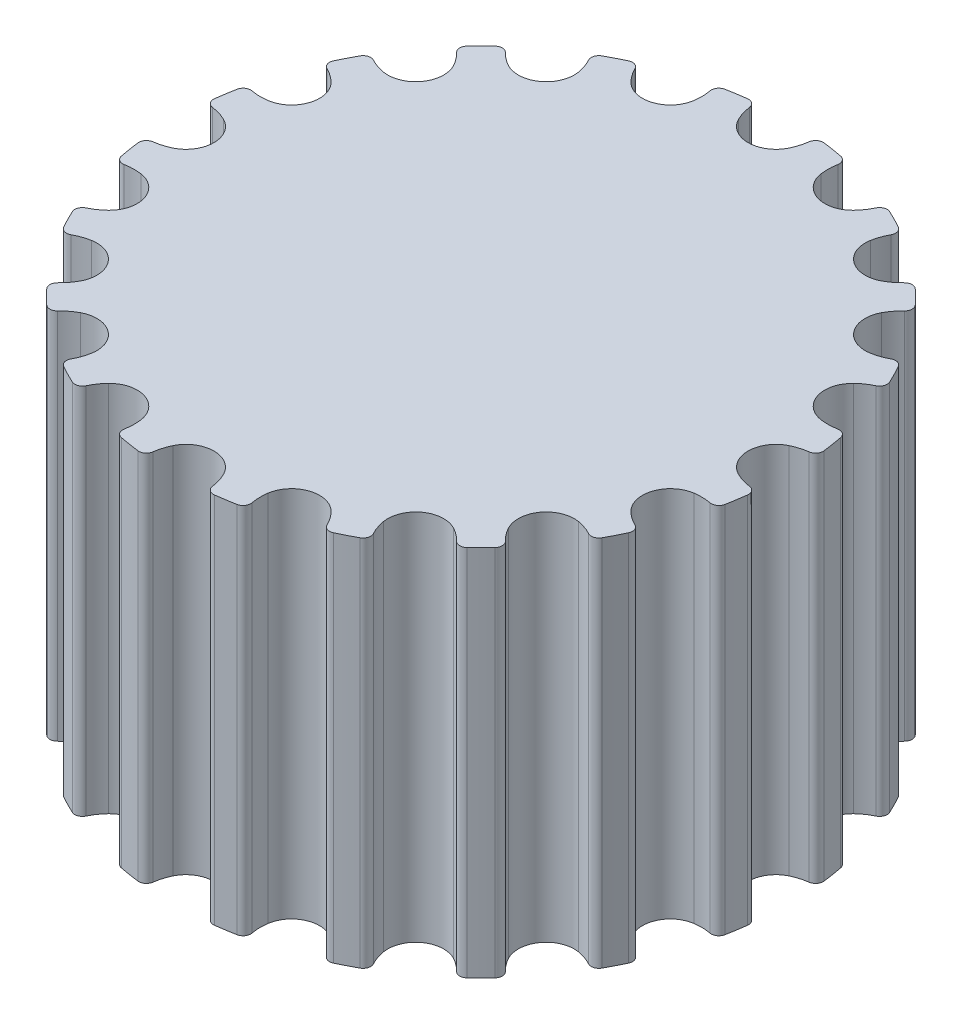
from build123d import *

# Parameters (mm, degrees)
SKETCH1_R           = 6.1
BOSS_EXTRUDE1_DEPTH = 7.4
CUT_EXTRUDE2_DEPTH  = 7.4
CIRPATTERN1_COUNT   = 20


with BuildPart() as part:
    # Sketch1 → Boss-Extrude1 (new body)
    with BuildSketch(Plane(origin=(0, 0, 0), x_dir=(1, 0, 0), z_dir=(0, 1, 0))):
        Circle(SKETCH1_R)
    extrude(amount=BOSS_EXTRUDE1_DEPTH)

    # Sketch2 → Cut-Extrude2 (cut)
    with BuildSketch(Plane(origin=(0, 7.4, 0), x_dir=(1, 0, 0), z_dir=(0, 1, 0))):
        with BuildLine():
            Line((-38.373637849, 1.335743881), (-0.758991905, 6.05259707))
            ThreePointArc((-0.758991905, 6.05259707), (-0.648582224, 6.02243319), (-0.591589713, 5.923175892))
            ThreePointArc((-0.591589713, 5.923175892), (-0.557758828, 5.765024422), (-0.498876404, 5.614394822))
            ThreePointArc((-0.498876404, 5.614394822), (0, 5.30259707), (0.498876404, 5.614394822))
            ThreePointArc((0.498876404, 5.614394822), (0.557758828, 5.765024422), (0.591589713, 5.923175892))
            ThreePointArc((0.591589713, 5.923175892), (0.648582224, 6.02243319), (0.758991905, 6.05259707))
            Line((0.758991905, 6.05259707), (38.373637849, 1.335743881))
            Line((38.373637849, 1.335743881), (38.373637849, 77.154219029))
            Line((38.373637849, 77.154219029), (-38.373637849, 77.154219029))
            Line((-38.373637849, 77.154219029), (-38.373637849, 1.335743881))
        make_face()
    cut_extrude2 = extrude(amount=-CUT_EXTRUDE2_DEPTH, mode=Mode.SUBTRACT)

    # CirPattern1: Cut-Extrude2 ×20 about axis
    cirpattern1_axis = Axis((0, 0, 0), (0, 1, 0))
    for i in range(1, CIRPATTERN1_COUNT):
        add(cut_extrude2.rotate(cirpattern1_axis, i * 360 / CIRPATTERN1_COUNT), mode=Mode.SUBTRACT)


solid = part.part
